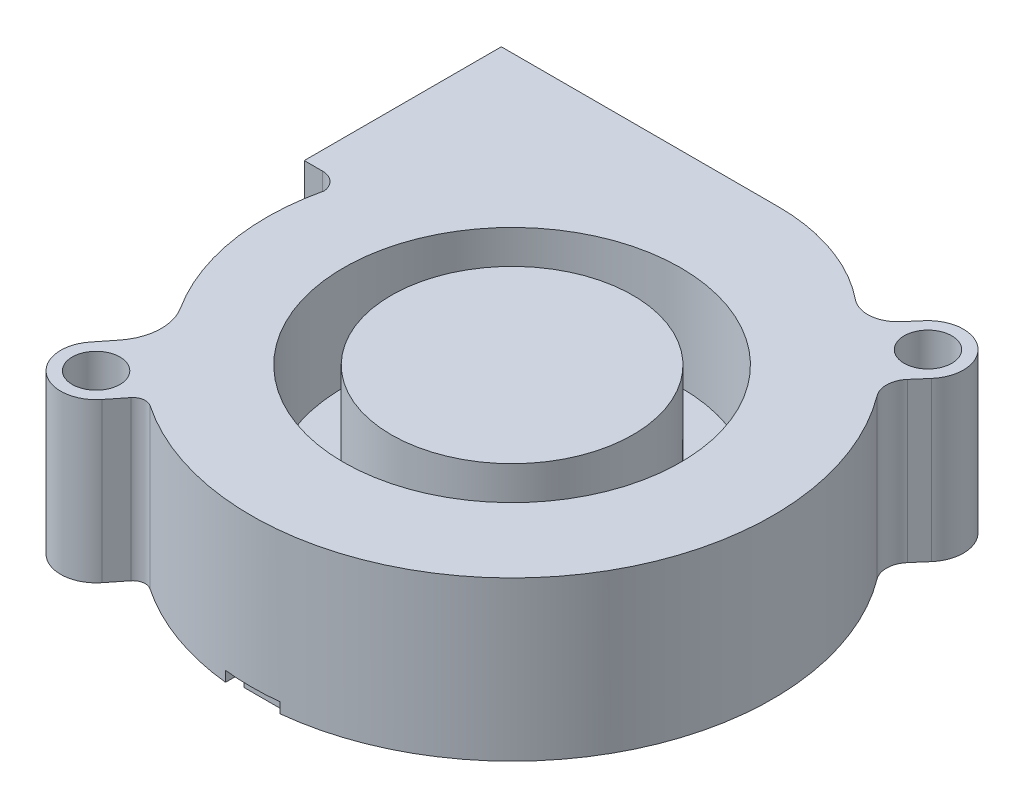
from build123d import *

# Parameters (mm, degrees)
BOSS_EXTRUDE1_DEPTH = 15.3
SKETCH2_R           = 2.3
CUT_EXTRUDE1_DEPTH  = 16.3
SKETCH3_R           = 16.25
SKETCH3_R_2         = 11.65
CUT_EXTRUDE2_DEPTH  = 10
SKETCH4_W           = 16.4
SKETCH4_H           = 12.7
CUT_EXTRUDE3_DEPTH  = 5
CUT_EXTRUDE6_DEPTH  = 1
CUT_EXTRUDE7_DEPTH  = 0.5


with BuildPart() as part:
    # Sketch1 → Boss-Extrude1 (new body)
    with BuildSketch(Plane(origin=(0, 0, 0), x_dir=(1, 0, 0), z_dir=(0, 1, 0))):
        with BuildLine():
            Line((0, 0), (0, 19))
            Line((0, 19), (26.7, 19))
            ThreePointArc((26.7, 19), (32.797644088, 17.95548785), (38.2, 14.941052635))
            ThreePointArc((38.2, 14.941052635), (40.271433107, 14.311273646), (42.2, 15.295187477))
            Line((42.2, 15.295187477), (43.269443579, 16.525441584))
            ThreePointArc((43.269443579, 16.525441584), (48.087218379, 16.862333216), (48.424110012, 12.044558416))
            Line((48.424110012, 12.044558416), (47.354666433, 10.814304309))
            ThreePointArc((47.354666433, 10.814304309), (46.801667822, 9.415462269), (47.248710238, 7.979245156))
            ThreePointArc((47.248710238, 7.979245156), (45.289416111, -24.409093359), (13.030186992, -27.899858595))
            ThreePointArc((13.030186992, -27.899858595), (12.183303759, -27.710109359), (11.432636129, -28.14567117))
            Line((11.432636129, -28.14567117), (10.187606856, -29.710887484))
            ThreePointArc((10.187606856, -29.710887484), (5.389112516, -30.257606856), (4.842393144, -25.459112516))
            Line((4.842393144, -25.459112516), (6.087422418, -23.893896202))
            ThreePointArc((6.087422418, -23.893896202), (7.124082388, -21.152735596), (6.372856996, -18.320018566))
            ThreePointArc((6.372856996, -18.320018566), (3.237759838, -10.229166003), (3.5, -1.556106595))
            ThreePointArc((3.5, -1.556106595), (2.927161914, -0.445774177), (1.76, 0))
            Line((1.76, 0), (0, 0))
        make_face()
    extrude(amount=BOSS_EXTRUDE1_DEPTH)

    # Sketch2 → Cut-Extrude1 (cut, through all)
    with BuildSketch(Plane(origin=(0, 15.3, 0), x_dir=(1, 0, 0), z_dir=(0, 1, 0))):
        with Locations((45.846776795, 14.285)):
            Circle(SKETCH2_R)
        with Locations((7.515, -27.585)):
            Circle(SKETCH2_R)
    extrude(amount=-CUT_EXTRUDE1_DEPTH, mode=Mode.SUBTRACT)

    # Sketch3 → Cut-Extrude2 (cut)
    with BuildSketch(Plane(origin=(0, 15.3, 0), x_dir=(1, 0, 0), z_dir=(0, 1, 0))):
        with Locations((27.093039229, -7.054893275)):
            Circle(SKETCH3_R)
        with Locations((27.093039229, -7.054893275)):
            Circle(SKETCH3_R_2, mode=Mode.SUBTRACT)
    extrude(amount=-CUT_EXTRUDE2_DEPTH, mode=Mode.SUBTRACT)

    # Sketch4 → Cut-Extrude3 (cut)
    with BuildSketch(Plane.ZY):
        with Locations((-9.5, 7.65)):
            Rectangle(SKETCH4_W, SKETCH4_H)
    extrude(amount=-CUT_EXTRUDE3_DEPTH, mode=Mode.SUBTRACT)

    # Sketch5 → Cut-Extrude6 (cut)
    with BuildSketch(Plane.XZ):
        Polygon((24.473039229, 32.3), (24.473039229, 22.4), (29.713039229, 22.4), (29.713039229, 30.3), (25.773039229, 30.3), (25.773039229, 31.6), (29.713039229, 31.6), (29.713039229, 32.3), align=None)
    extrude(amount=-CUT_EXTRUDE6_DEPTH, mode=Mode.SUBTRACT)

    # Sketch6 → Cut-Extrude7 (cut)
    with BuildSketch(Plane.XZ):
        with BuildLine():
            ThreePointArc((20.446034334, 16.982126203), (28.294472835, 19.55144458), (35.841272267, 16.198057911))
            Line((35.841272267, 16.198057911), (43.97300025, 24.329785894))
            ThreePointArc((43.97300025, 24.329785894), (35.608102686, 29.66755154), (25.773039229, 30.984662069))
            Line((25.773039229, 30.984662069), (25.773039229, 30.3))
            Line((25.773039229, 30.3), (29.713039229, 30.3))
            Line((29.713039229, 30.3), (29.713039229, 22.4))
            Line((29.713039229, 22.4), (24.473039229, 22.4))
            Line((24.473039229, 22.4), (24.473039229, 30.837474717))
            ThreePointArc((24.473039229, 30.837474717), (17.69194169, 28.770137265), (11.862557451, 24.735853266))
            Line((11.862557451, 24.735853266), (20.446034334, 16.982126203))
        make_face()
        with BuildLine():
            ThreePointArc((16.242880644, 8.941329927), (17.141710334, 12.601843748), (19.175813557, 15.775119708))
            Line((19.175813557, 15.775119708), (10.642082831, 23.48390949))
            ThreePointArc((10.642082831, 23.48390949), (6.404884497, 16.733017379), (4.726194331, 8.941329927))
            Line((4.726194331, 8.941329927), (16.242880644, 8.941329927))
        make_face()
        with BuildLine():
            ThreePointArc((18.982670233, 0.576892744), (17.084929659, 3.665470455), (16.242880644, 7.191329927))
            Line((16.242880644, 7.191329927), (4.726194331, 7.191329927))
            ThreePointArc((4.726194331, 7.191329927), (6.460315035, -0.735389017), (10.839143244, -7.566634245))
            Line((10.839143244, -7.566634245), (18.982670233, 0.576892744))
        make_face()
        with BuildLine():
            ThreePointArc((25.962402252, -3.30017766), (22.906366669, -2.382568809), (20.2201071, -0.660544123))
            Line((20.2201071, -0.660544123), (12.076580111, -8.804071112))
            ThreePointArc((12.076580111, -8.804071112), (18.505879136, -13.011918289), (25.962402252, -14.867215257))
            Line((25.962402252, -14.867215257), (25.962402252, -3.30017766))
        make_face()
        with BuildLine():
            Line((43.342508455, -8.804071112), (35.198981466, -0.660544123))
            ThreePointArc((35.198981466, -0.660544123), (31.702722743, -2.718127676), (27.709544283, -3.433670073))
            Line((27.709544283, -3.433670073), (27.709544283, -14.933670073))
            ThreePointArc((27.709544283, -14.933670073), (36.105399692, -13.346507623), (43.342508455, -8.804071112))
        make_face()
        with BuildLine():
            Line((50.692894235, 7.191329927), (39.176207922, 7.191329927))
            ThreePointArc((39.176207922, 7.191329927), (38.334158907, 3.665470455), (36.436418333, 0.576892744))
            Line((36.436418333, 0.576892744), (44.579945322, -7.566634245))
            ThreePointArc((44.579945322, -7.566634245), (48.958773531, -0.735389017), (50.692894235, 7.191329927))
        make_face()
        with BuildLine():
            Line((45.161425577, 23.047379266), (36.982294854, 14.868248542))
            ThreePointArc((36.982294854, 14.868248542), (38.494390898, 12.058457617), (39.176207922, 8.941329927))
            Line((39.176207922, 8.941329927), (50.692894235, 8.941329927))
            ThreePointArc((50.692894235, 8.941329927), (49.122090569, 16.462928139), (45.161425577, 23.047379266))
        make_face()
    extrude(amount=-CUT_EXTRUDE7_DEPTH, mode=Mode.SUBTRACT)


solid = part.part
